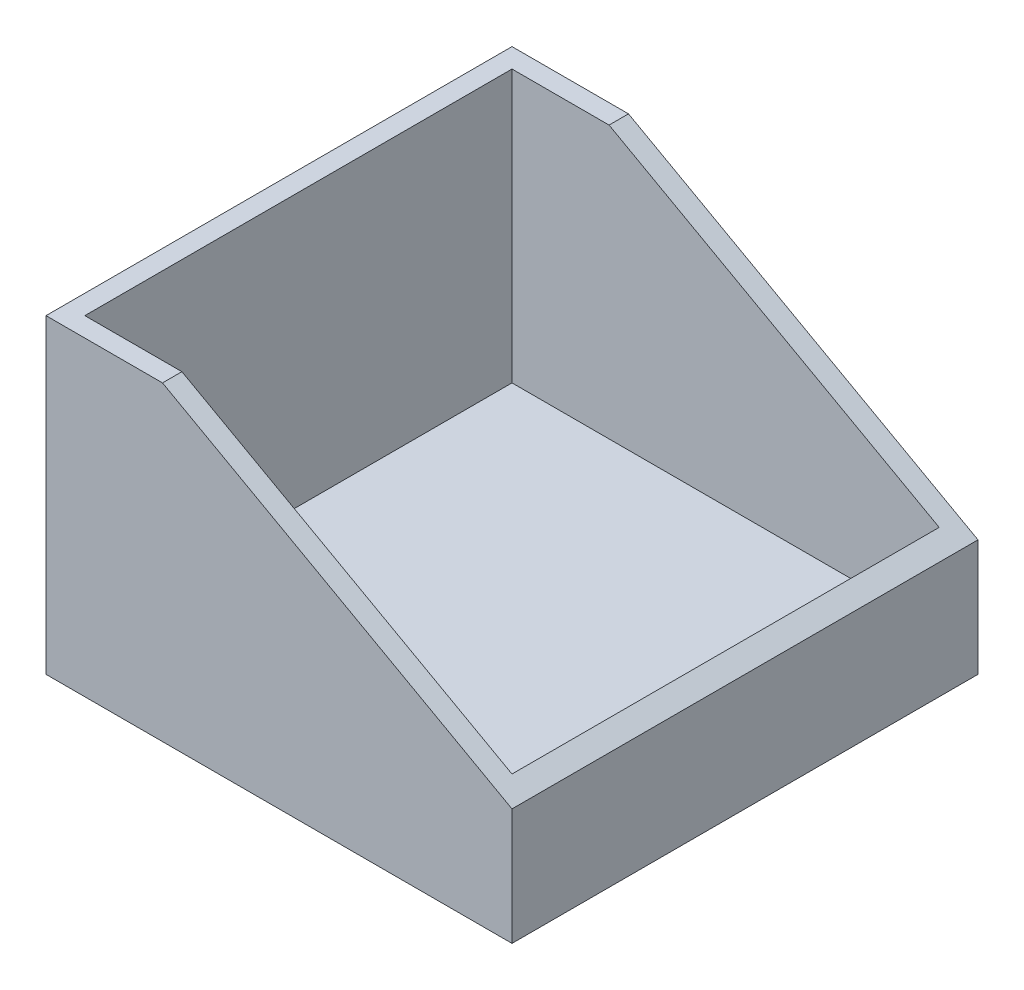
from build123d import *

# Parameters (mm, degrees)
SKETCH1_W           = 152.4
SKETCH1_H           = 101.6
BOSS_EXTRUDE1_DEPTH = 152.4
CUT_EXTRUDE2_DEPTH  = 152.4
SKETCH7_W           = 139.7
SKETCH7_H           = 139.7
CUT_EXTRUDE3_DEPTH  = 88.9


with BuildPart() as part:
    # Sketch1 → Boss-Extrude1 (new body)
    with BuildSketch(Plane.XY):
        with Locations((76.2, 50.8)):
            Rectangle(SKETCH1_W, SKETCH1_H)
    extrude(amount=BOSS_EXTRUDE1_DEPTH)

    # Sketch6 → Cut-Extrude2 (cut)
    with BuildSketch(Plane.XY.offset(152.4)):
        Polygon((104.436678767, 101.6), (38.1, 101.6), (152.4, 38.1), (152.4, 101.6), (104.590197544, 101.6), align=None)
    extrude(amount=-CUT_EXTRUDE2_DEPTH, mode=Mode.SUBTRACT)

    # Sketch7 → Cut-Extrude3 (cut)
    with BuildSketch(Plane(origin=(0, 101.6, 0), x_dir=(1, 0, 0), z_dir=(0, 1, 0))):
        with Locations((76.2, -76.2)):
            Rectangle(SKETCH7_W, SKETCH7_H)
    extrude(amount=-CUT_EXTRUDE3_DEPTH, mode=Mode.SUBTRACT)


solid = part.part
